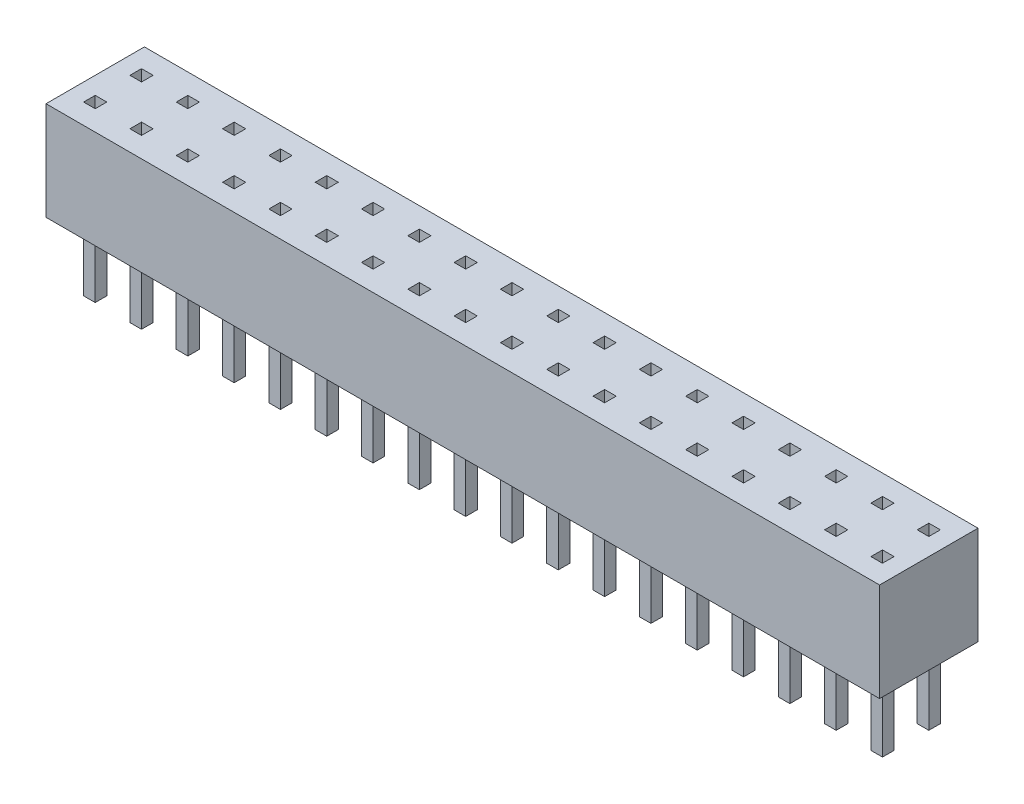
from build123d import *

# Parameters (mm, degrees)
SKETCH1_W           = 36
SKETCH1_H           = 4.25
BOSS_EXTRUDE1_DEPTH = 4.25
SKETCH3_W           = 0.5
SKETCH3_H           = 0.5
BOSS_EXTRUDE2_DEPTH = 3
SKETCH4_W           = 0.5
SKETCH4_H           = 0.5
CUT_EXTRUDE1_DEPTH  = 4


with BuildPart() as part:
    # Sketch1 → Boss-Extrude1 (new body)
    with BuildSketch(Plane(origin=(0, 0, 0), x_dir=(1, 0, 0), z_dir=(0, 1, 0))):
        with Locations((18, -2.125)):
            Rectangle(SKETCH1_W, SKETCH1_H)
    extrude(amount=BOSS_EXTRUDE1_DEPTH)

    # Sketch3 → Boss-Extrude2 (add)
    with BuildSketch(Plane.XZ):
        with Locations((3, 1.125)):
            Rectangle(SKETCH3_W, SKETCH3_H)
        with Locations((1, 1.125)):
            Rectangle(SKETCH3_W, SKETCH3_H)
        with Locations((5, 1.125)):
            Rectangle(SKETCH3_W, SKETCH3_H)
        with Locations((7, 1.125)):
            Rectangle(SKETCH3_W, SKETCH3_H)
        with Locations((9, 1.125)):
            Rectangle(SKETCH3_W, SKETCH3_H)
        with Locations((11, 1.125)):
            Rectangle(SKETCH3_W, SKETCH3_H)
        with Locations((13, 1.125)):
            Rectangle(SKETCH3_W, SKETCH3_H)
        with Locations((15, 1.125)):
            Rectangle(SKETCH3_W, SKETCH3_H)
        with Locations((17, 1.125)):
            Rectangle(SKETCH3_W, SKETCH3_H)
        with Locations((19, 1.125)):
            Rectangle(SKETCH3_W, SKETCH3_H)
        with Locations((21, 1.125)):
            Rectangle(SKETCH3_W, SKETCH3_H)
        with Locations((23, 1.125)):
            Rectangle(SKETCH3_W, SKETCH3_H)
        with Locations((25, 1.125)):
            Rectangle(SKETCH3_W, SKETCH3_H)
        with Locations((27, 1.125)):
            Rectangle(SKETCH3_W, SKETCH3_H)
        with Locations((29, 1.125)):
            Rectangle(SKETCH3_W, SKETCH3_H)
        with Locations((31, 1.125)):
            Rectangle(SKETCH3_W, SKETCH3_H)
        with Locations((33, 1.125)):
            Rectangle(SKETCH3_W, SKETCH3_H)
        with Locations((35, 1.125)):
            Rectangle(SKETCH3_W, SKETCH3_H)
        with Locations((1, 3.125)):
            Rectangle(SKETCH3_W, SKETCH3_H)
        with Locations((3, 3.125)):
            Rectangle(SKETCH3_W, SKETCH3_H)
        with Locations((5, 3.125)):
            Rectangle(SKETCH3_W, SKETCH3_H)
        with Locations((7, 3.125)):
            Rectangle(SKETCH3_W, SKETCH3_H)
        with Locations((9, 3.125)):
            Rectangle(SKETCH3_W, SKETCH3_H)
        with Locations((11, 3.125)):
            Rectangle(SKETCH3_W, SKETCH3_H)
        with Locations((13, 3.125)):
            Rectangle(SKETCH3_W, SKETCH3_H)
        with Locations((15, 3.125)):
            Rectangle(SKETCH3_W, SKETCH3_H)
        with Locations((17, 3.125)):
            Rectangle(SKETCH3_W, SKETCH3_H)
        with Locations((19, 3.125)):
            Rectangle(SKETCH3_W, SKETCH3_H)
        with Locations((21, 3.125)):
            Rectangle(SKETCH3_W, SKETCH3_H)
        with Locations((23, 3.125)):
            Rectangle(SKETCH3_W, SKETCH3_H)
        with Locations((25, 3.125)):
            Rectangle(SKETCH3_W, SKETCH3_H)
        with Locations((27, 3.125)):
            Rectangle(SKETCH3_W, SKETCH3_H)
        with Locations((29, 3.125)):
            Rectangle(SKETCH3_W, SKETCH3_H)
        with Locations((31, 3.125)):
            Rectangle(SKETCH3_W, SKETCH3_H)
        with Locations((33, 3.125)):
            Rectangle(SKETCH3_W, SKETCH3_H)
        with Locations((35, 3.125)):
            Rectangle(SKETCH3_W, SKETCH3_H)
    extrude(amount=BOSS_EXTRUDE2_DEPTH)

    # Sketch4 → Cut-Extrude1 (cut)
    with BuildSketch(Plane(origin=(0, 4.25, 0), x_dir=(-1, 0, 0), z_dir=(0, 1, 0))):
        with Locations((-33, 1.125)):
            Rectangle(SKETCH4_W, SKETCH4_H)
        with Locations((-35, 1.125)):
            Rectangle(SKETCH4_W, SKETCH4_H)
        with Locations((-31, 1.125)):
            Rectangle(SKETCH4_W, SKETCH4_H)
        with Locations((-29, 1.125)):
            Rectangle(SKETCH4_W, SKETCH4_H)
        with Locations((-27, 1.125)):
            Rectangle(SKETCH4_W, SKETCH4_H)
        with Locations((-25, 1.125)):
            Rectangle(SKETCH4_W, SKETCH4_H)
        with Locations((-23, 1.125)):
            Rectangle(SKETCH4_W, SKETCH4_H)
        with Locations((-21, 1.125)):
            Rectangle(SKETCH4_W, SKETCH4_H)
        with Locations((-19, 1.125)):
            Rectangle(SKETCH4_W, SKETCH4_H)
        with Locations((-17, 1.125)):
            Rectangle(SKETCH4_W, SKETCH4_H)
        with Locations((-15, 1.125)):
            Rectangle(SKETCH4_W, SKETCH4_H)
        with Locations((-13, 1.125)):
            Rectangle(SKETCH4_W, SKETCH4_H)
        with Locations((-11, 1.125)):
            Rectangle(SKETCH4_W, SKETCH4_H)
        with Locations((-9, 1.125)):
            Rectangle(SKETCH4_W, SKETCH4_H)
        with Locations((-7, 1.125)):
            Rectangle(SKETCH4_W, SKETCH4_H)
        with Locations((-5, 1.125)):
            Rectangle(SKETCH4_W, SKETCH4_H)
        with Locations((-3, 1.125)):
            Rectangle(SKETCH4_W, SKETCH4_H)
        with Locations((-1, 1.125)):
            Rectangle(SKETCH4_W, SKETCH4_H)
        with Locations((-35, 3.125)):
            Rectangle(SKETCH4_W, SKETCH4_H)
        with Locations((-33, 3.125)):
            Rectangle(SKETCH4_W, SKETCH4_H)
        with Locations((-31, 3.125)):
            Rectangle(SKETCH4_W, SKETCH4_H)
        with Locations((-29, 3.125)):
            Rectangle(SKETCH4_W, SKETCH4_H)
        with Locations((-27, 3.125)):
            Rectangle(SKETCH4_W, SKETCH4_H)
        with Locations((-25, 3.125)):
            Rectangle(SKETCH4_W, SKETCH4_H)
        with Locations((-23, 3.125)):
            Rectangle(SKETCH4_W, SKETCH4_H)
        with Locations((-21, 3.125)):
            Rectangle(SKETCH4_W, SKETCH4_H)
        with Locations((-19, 3.125)):
            Rectangle(SKETCH4_W, SKETCH4_H)
        with Locations((-17, 3.125)):
            Rectangle(SKETCH4_W, SKETCH4_H)
        with Locations((-15, 3.125)):
            Rectangle(SKETCH4_W, SKETCH4_H)
        with Locations((-13, 3.125)):
            Rectangle(SKETCH4_W, SKETCH4_H)
        with Locations((-11, 3.125)):
            Rectangle(SKETCH4_W, SKETCH4_H)
        with Locations((-9, 3.125)):
            Rectangle(SKETCH4_W, SKETCH4_H)
        with Locations((-7, 3.125)):
            Rectangle(SKETCH4_W, SKETCH4_H)
        with Locations((-5, 3.125)):
            Rectangle(SKETCH4_W, SKETCH4_H)
        with Locations((-3, 3.125)):
            Rectangle(SKETCH4_W, SKETCH4_H)
        with Locations((-1, 3.125)):
            Rectangle(SKETCH4_W, SKETCH4_H)
    extrude(amount=-CUT_EXTRUDE1_DEPTH, mode=Mode.SUBTRACT)


solid = part.part
